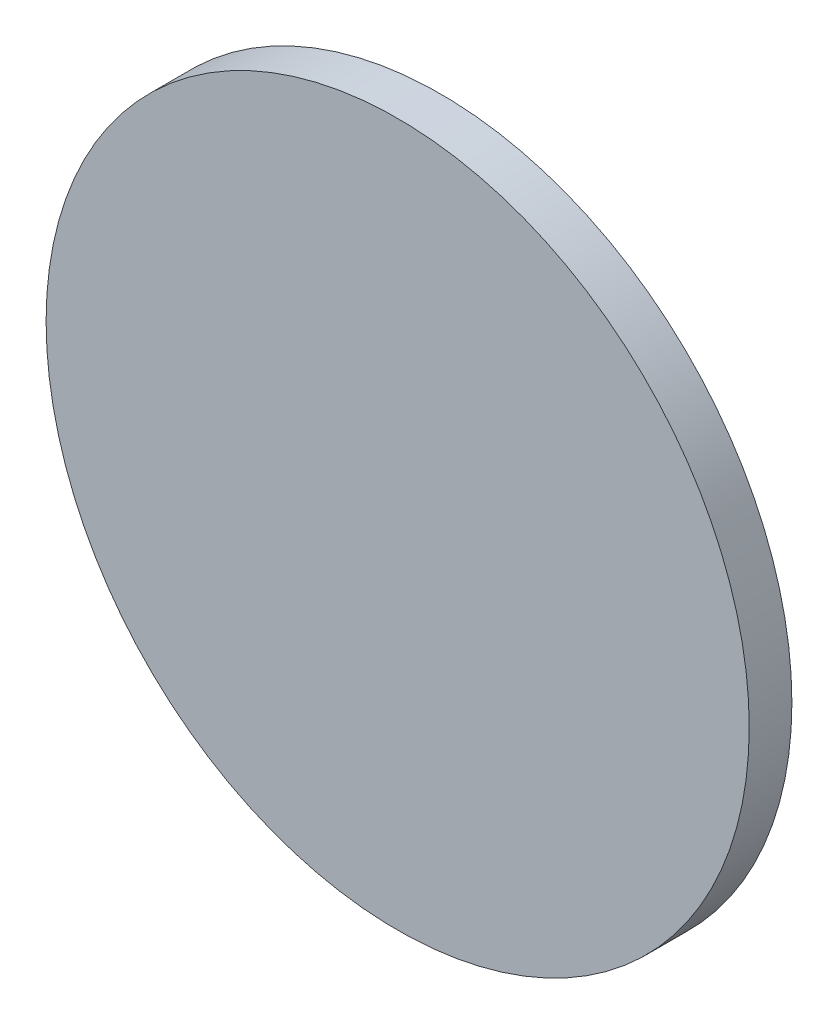
from build123d import *

# Parameters (mm, degrees)
SKETCH1_R           = 75
BOSS_EXTRUDE1_DEPTH = 9.1


with BuildPart() as part:
    # Sketch1 → Boss-Extrude1 (new body)
    with BuildSketch(Plane.XY):
        Circle(SKETCH1_R)
    extrude(amount=BOSS_EXTRUDE1_DEPTH)


solid = part.part
